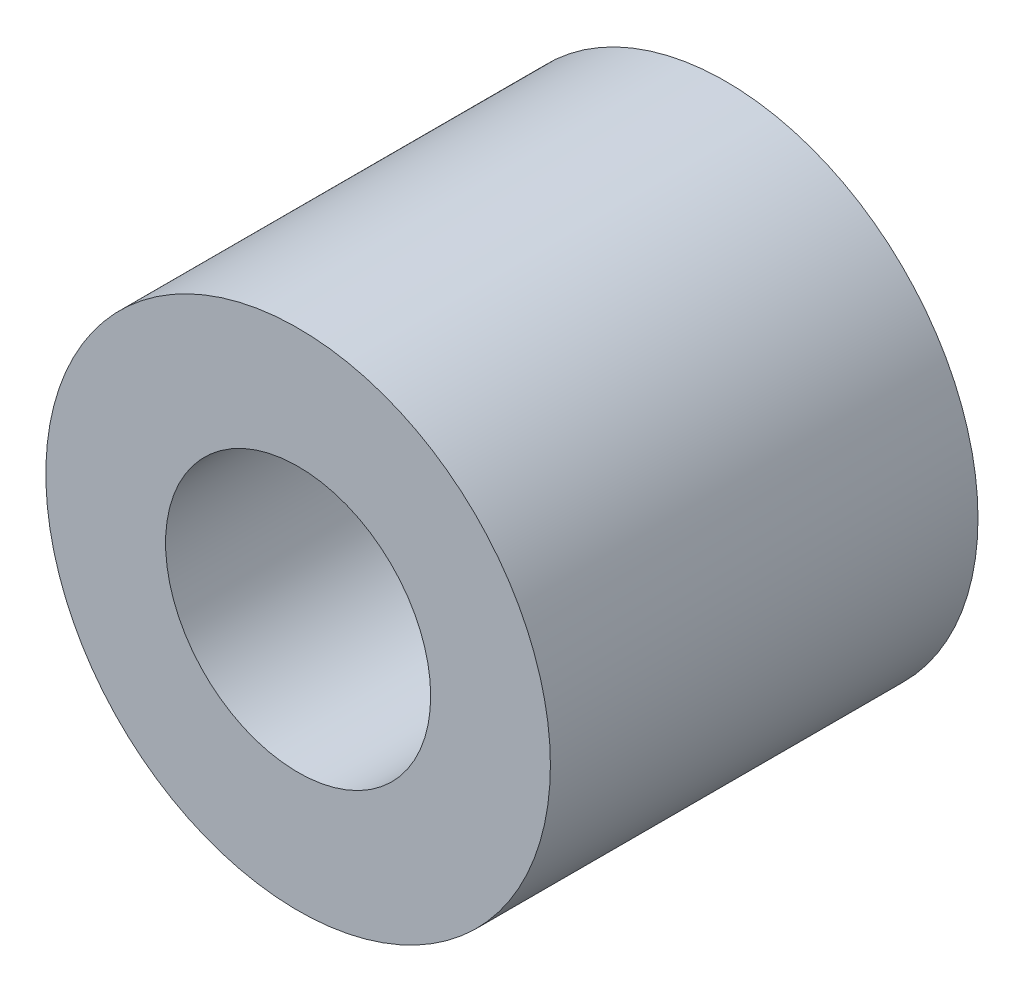
from build123d import *

# Parameters (mm, degrees)
SKETCH1_R           = 2.95
BOSS_EXTRUDE1_DEPTH = 5
SKETCH4_R           = 1.55
CUT_EXTRUDE1_DEPTH  = 6


with BuildPart() as part:
    # Sketch1 → Boss-Extrude1 (new body)
    with BuildSketch(Plane.XY):
        Circle(SKETCH1_R)
    extrude(amount=BOSS_EXTRUDE1_DEPTH)

    # Sketch4 → Cut-Extrude1 (cut, through all)
    with BuildSketch(Plane.XY.offset(5)):
        Circle(SKETCH4_R)
    extrude(amount=-CUT_EXTRUDE1_DEPTH, mode=Mode.SUBTRACT)


solid = part.part
